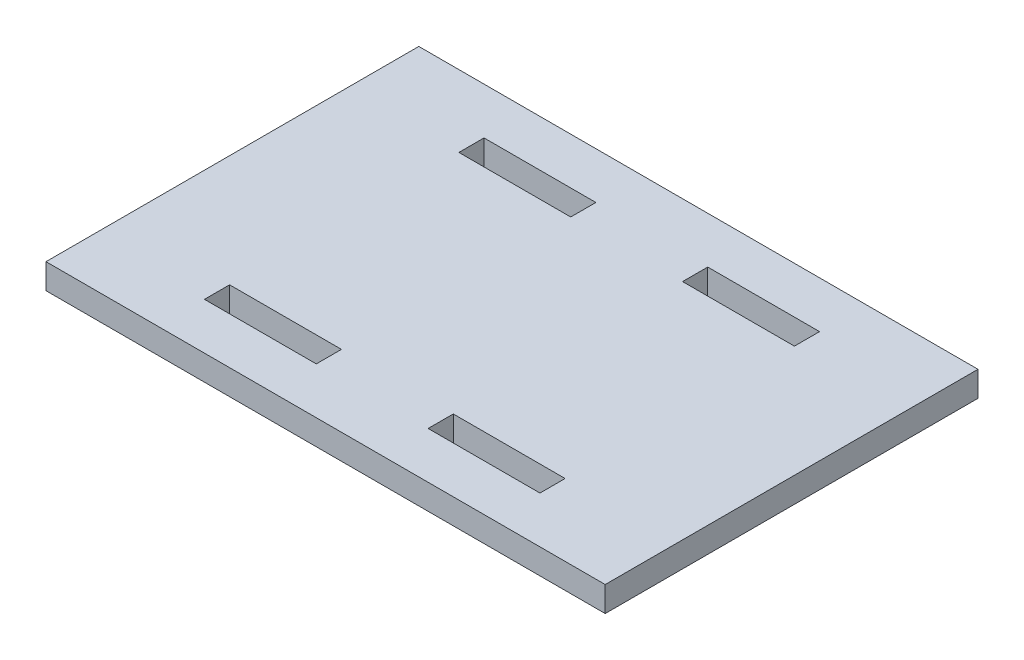
from build123d import *

# Parameters (mm, degrees)
SKETCH1_W           = 60
SKETCH1_H           = 40
SKETCH1_W_2         = 12
SKETCH1_H_2         = 2.7
BOSS_EXTRUDE1_DEPTH = 2.7


with BuildPart() as part:
    # Sketch1 → Boss-Extrude1 (new body)
    with BuildSketch(Plane(origin=(0, 0, 0), x_dir=(1, 0, 0), z_dir=(0, 1, 0))):
        Rectangle(SKETCH1_W, SKETCH1_H)
        with Locations((-12, 13.65)):
            Rectangle(SKETCH1_W_2, SKETCH1_H_2, mode=Mode.SUBTRACT)
        with Locations((12, 13.65)):
            Rectangle(SKETCH1_W_2, SKETCH1_H_2, mode=Mode.SUBTRACT)
        with Locations((12, -13.65)):
            Rectangle(SKETCH1_W_2, SKETCH1_H_2, mode=Mode.SUBTRACT)
        with Locations((-12, -13.65)):
            Rectangle(SKETCH1_W_2, SKETCH1_H_2, mode=Mode.SUBTRACT)
    extrude(amount=-BOSS_EXTRUDE1_DEPTH)


solid = part.part
